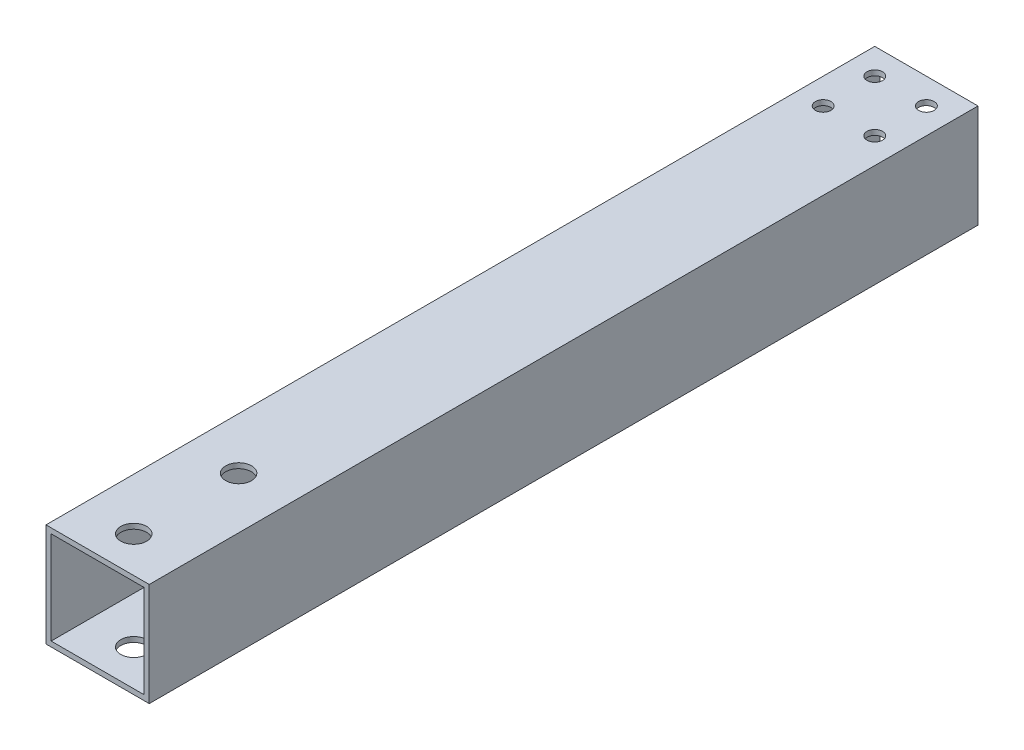
from build123d import *

# Parameters (mm, degrees)
SKETCH_1_W          = 20
SKETCH_1_H          = 20
SKETCH_1_W_2        = 18
SKETCH_1_H_2        = 18
EXTRUDE_1_DEPTH     = 171.98
SKETCH_2_R          = 1.5
CUT_EXTRUDE_1_DEPTH = 50
SKETCH_4_W          = 20
SKETCH_4_H          = 8.4
CUT_EXTRUDE_2_DEPTH = 21
SKETCH_5_R          = 2.5
CUT_EXTRUDE_3_DEPTH = 36
SKETCH_6_W          = 20
SKETCH_6_H          = 3
CUT_EXTRUDE_4_DEPTH = 33


with BuildPart() as part:
    # 草图1 → 凸台-拉伸1 (new body)
    with BuildSketch(Plane.XY):
        Rectangle(SKETCH_1_W, SKETCH_1_H)
        Rectangle(SKETCH_1_W_2, SKETCH_1_H_2, mode=Mode.SUBTRACT)
    extrude(amount=EXTRUDE_1_DEPTH)

    # 草图2 → 切除-拉伸1 (cut)
    with BuildSketch(Plane(origin=(0, 10, 0), x_dir=(1, 0, 0), z_dir=(0, 1, 0))):
        with Locations((-5, -5)):
            Circle(SKETCH_2_R)
        with Locations((5, -5)):
            Circle(SKETCH_2_R)
        with Locations((-5, -15)):
            Circle(SKETCH_2_R)
        with Locations((5, -15)):
            Circle(SKETCH_2_R)
        with Locations((-5, -235)):
            Circle(SKETCH_2_R)
        with Locations((5, -245)):
            Circle(SKETCH_2_R)
        with Locations((5, -235)):
            Circle(SKETCH_2_R)
        with Locations((-5, -245)):
            Circle(SKETCH_2_R)
    extrude(amount=-CUT_EXTRUDE_1_DEPTH, mode=Mode.SUBTRACT)

    # 草图4 → 切除-拉伸2 (cut, through all)
    with BuildSketch(Plane.XZ.offset(10)):
        with Locations((0, 167.78)):
            Rectangle(SKETCH_4_W, SKETCH_4_H)
    extrude(amount=-CUT_EXTRUDE_2_DEPTH, mode=Mode.SUBTRACT)

    # 草图5 → 切除-拉伸3 (cut)
    with BuildSketch(Plane(origin=(0, 10, 0), x_dir=(1, 0, 0), z_dir=(0, 1, 0))):
        with Locations((0, -153.58)):
            Circle(SKETCH_5_R)
        with Locations((0, -133.26)):
            Circle(SKETCH_5_R)
    extrude(amount=-CUT_EXTRUDE_3_DEPTH, mode=Mode.SUBTRACT)

    # 草图6 → 切除-拉伸4 (cut)
    with BuildSketch(Plane(origin=(0, 10, 0), x_dir=(1, 0, 0), z_dir=(0, 1, 0))):
        with Locations((0, -162.08)):
            Rectangle(SKETCH_6_W, SKETCH_6_H)
    extrude(amount=-CUT_EXTRUDE_4_DEPTH, mode=Mode.SUBTRACT)


solid = part.part
